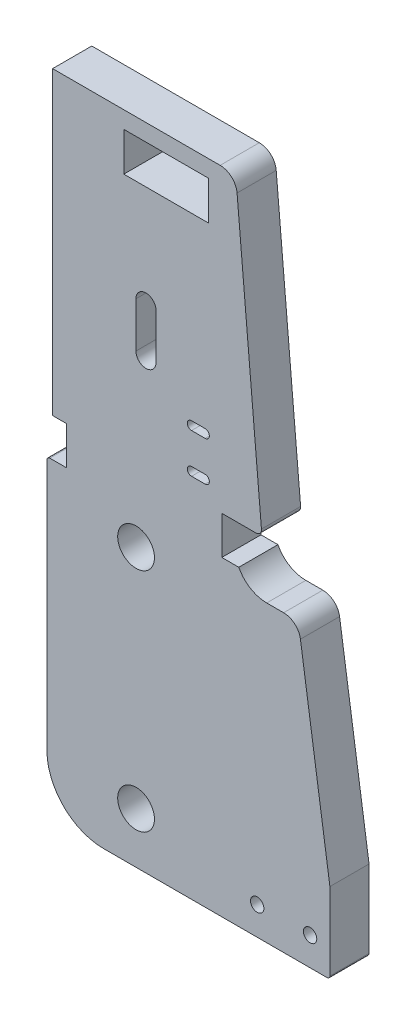
from build123d import *

# Parameters (mm, degrees)
SKETCH1_R           = 3.25
SKETCH1_R_2         = 1.1811
SKETCH1_W           = 15
SKETCH1_H           = 6.858
BOSS_EXTRUDE1_DEPTH = 6.92


with BuildPart() as part:
    # Sketch1 → Boss-Extrude1 (new body)
    with BuildSketch(Plane.XY):
        with BuildLine():
            Line((54.449901472, -1.5), (93.949901472, -1.5))
            ThreePointArc((93.949901472, -1.5), (94.303454863, -1.353553391), (94.449901472, -1))
            Line((94.449901472, -1), (94.449901472, 12.686692025))
            Line((94.449901472, 12.686692025), (89.243377961, 47.938332641))
            ThreePointArc((89.243377961, 47.938332641), (88.235803145, 49.771012761), (86.275573302, 50.5))
            Line((86.275573302, 50.5), (83.280158812, 50.5))
            ThreePointArc((83.280158812, 50.5), (80.394529009, 51.308940401), (78.349901472, 53.5))
            Line((78.349901472, 53.5), (75.349901472, 53.5))
            Line((75.349901472, 53.5), (75.349901472, 60.26))
            Line((75.349901472, 60.26), (81.358592971, 60.26))
            ThreePointArc((81.358592971, 60.26), (82.095870308, 60.584409792), (82.354787669, 61.347155743))
            Line((82.354787669, 61.347155743), (78.044018988, 110.619467228))
            ThreePointArc((78.044018988, 110.619467228), (77.082205517, 112.56983201), (75.055434894, 113.358))
            Line((75.055434894, 113.358), (45.449901472, 113.358))
            Line((45.449901472, 113.358), (45.449901472, 60.26))
            Line((45.449901472, 60.26), (47.949901472, 60.26))
            Line((47.949901472, 60.26), (47.949901472, 53.5))
            Line((47.949901472, 53.5), (44.949901472, 53.5))
            ThreePointArc((44.949901472, 53.5), (44.596348081, 53.353553391), (44.449901472, 53))
            Line((44.449901472, 53), (44.449901472, 8.5))
            ThreePointArc((44.449901472, 8.5), (47.37883366, 1.428932188), (54.449901472, -1.5))
        make_face()
        with Locations((60.199901472, 47.5)):
            Circle(SKETCH1_R, mode=Mode.SUBTRACT)
        with Locations((60.199901472, 7.5)):
            Circle(SKETCH1_R, mode=Mode.SUBTRACT)
        with Locations((81.602701472, 3.5)):
            Circle(SKETCH1_R_2, mode=Mode.SUBTRACT)
        with Locations((90.949901472, 3.5)):
            Circle(SKETCH1_R_2, mode=Mode.SUBTRACT)
        with BuildLine():
            Line((72.399901472, 63.25), (69.999901472, 63.25))
            ThreePointArc((69.999901472, 63.25), (69.249901472, 64), (69.999901472, 64.75))
            Line((69.999901472, 64.75), (72.399901472, 64.75))
            ThreePointArc((72.399901472, 64.75), (73.149901472, 64), (72.399901472, 63.25))
        make_face(mode=Mode.SUBTRACT)
        with BuildLine():
            Line((72.399901472, 70.25), (69.999901472, 70.25))
            ThreePointArc((69.999901472, 70.25), (69.249901472, 71), (69.999901472, 71.75))
            Line((69.999901472, 71.75), (72.399901472, 71.75))
            ThreePointArc((72.399901472, 71.75), (73.149901472, 71), (72.399901472, 70.25))
        make_face(mode=Mode.SUBTRACT)
        with BuildLine():
            Line((60.174901472, 77.5), (60.174901472, 85.5))
            ThreePointArc((60.174901472, 85.5), (61.949901472, 87.275), (63.724901472, 85.5))
            Line((63.724901472, 85.5), (63.724901472, 77.5))
            ThreePointArc((63.724901472, 77.5), (61.949901472, 75.725), (60.174901472, 77.5))
        make_face(mode=Mode.SUBTRACT)
        with Locations((65.533922881, 106.929)):
            Rectangle(SKETCH1_W, SKETCH1_H, mode=Mode.SUBTRACT)
    extrude(amount=BOSS_EXTRUDE1_DEPTH)


solid = part.part
